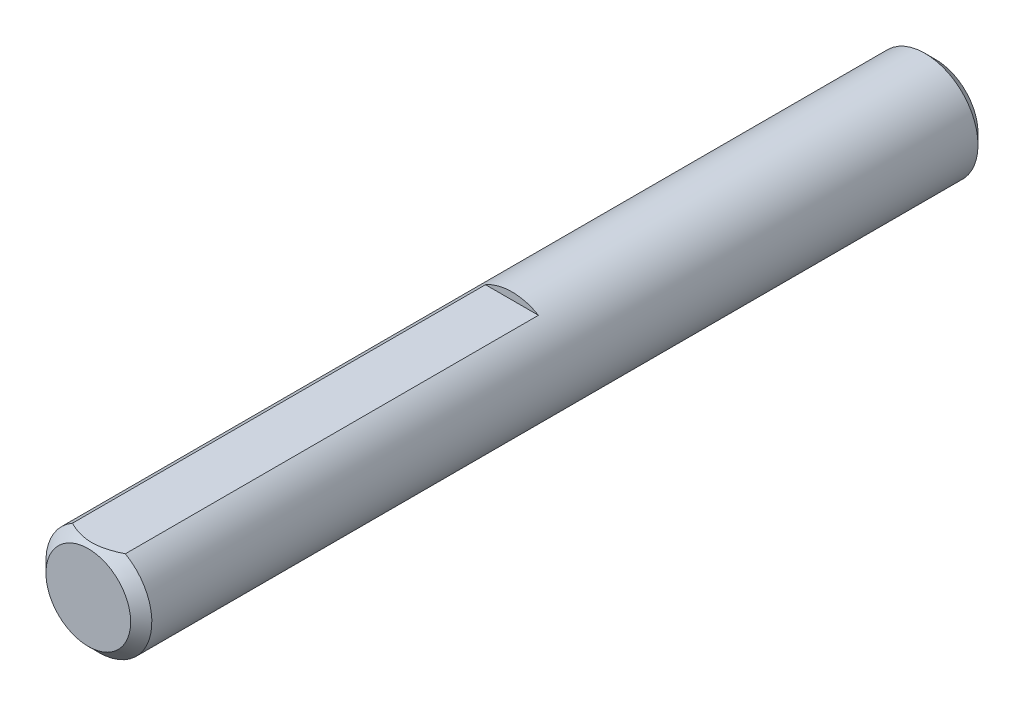
from build123d import *

# Parameters (mm, degrees)
SKETCH1_R      = 3.175
EXTRUDE1_DEPTH = 25.4
CHAMFER1_SIZE  = 0.635
EXTRUDE7_DEPTH = 26.4


with BuildPart() as part:
    # Sketch1 → Extrude1 (new body, symmetric)
    with BuildSketch(Plane.XY):
        Circle(SKETCH1_R)
    extrude(amount=EXTRUDE1_DEPTH, both=True)

    # Chamfer1
    chamfer1_edges = [part.edges().sort_by_distance(p)[0] for p in [
        (-3.175, 0, -25.4),
        (-3.175, 0, 25.4),
    ]]
    chamfer(chamfer1_edges, length=CHAMFER1_SIZE)

    # Sketch13 → Extrude7 (cut, through all)
    with BuildSketch(Plane.XY):
        with BuildLine():
            Line((-1.5875, 2.749630657), (1.5875, 2.749630657))
            ThreePointArc((1.5875, 2.749630657), (0, 3.175), (-1.5875, 2.749630657))
        make_face()
    extrude(amount=EXTRUDE7_DEPTH, mode=Mode.SUBTRACT)


solid = part.part
